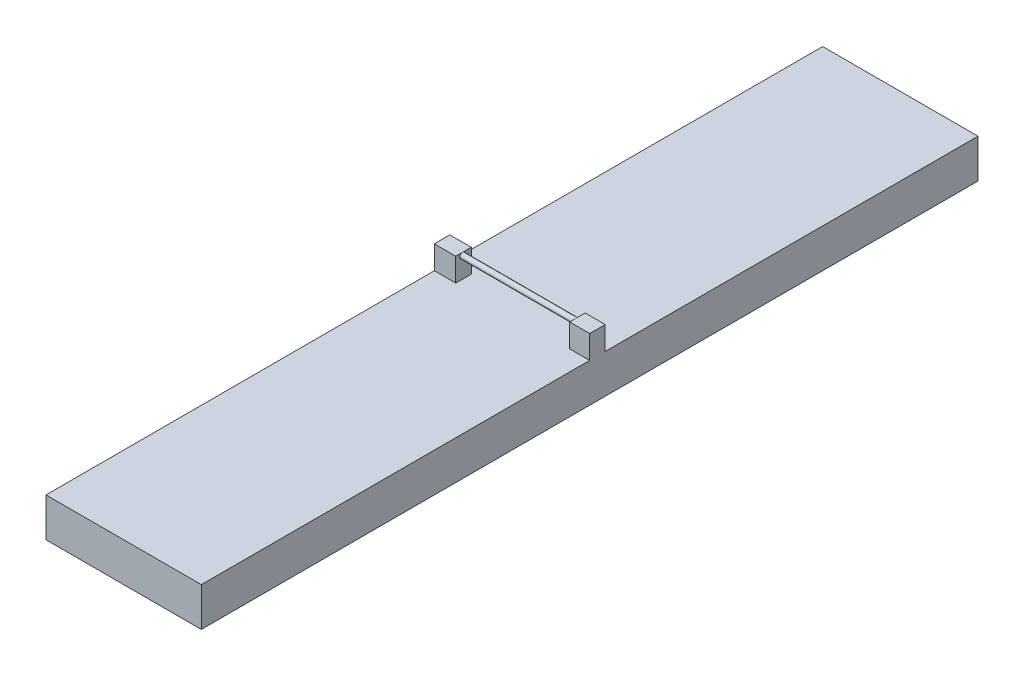
from build123d import *

# Parameters (mm, degrees)
BOSS_EXTRU_2_DEPTH      = 100
BOSS_EXTRU_2_DEPTH_BACK = 100
ESQUISSE3_W             = 1000
ESQUISSE3_H             = 50
ESQUISSE4_W             = 27.549124878
ESQUISSE4_H             = 20
ESQUISSE4_W_2           = 25.7645404
BOSS_EXTRU_4_DEPTH      = 30
BOSS_EXTRU_5_DEPTH      = 157
BOSS_EXTRU_5_DEPTH_BACK = 15
ESQUISSE7_R             = 3.448131388


with BuildPart() as part:
    # Esquisse3 → Boss.-Extru.2 (new, two sides: drawn at the far end of the back side and taken through both)
    with BuildSketch(Plane(origin=(0, 0, 0), x_dir=(0, 0, -1), z_dir=(1, 0, 0)).offset(-BOSS_EXTRU_2_DEPTH_BACK)):
        with Locations((450, 13.600000315)):
            Rectangle(ESQUISSE3_W, ESQUISSE3_H)
    extrude(amount=BOSS_EXTRU_2_DEPTH + BOSS_EXTRU_2_DEPTH_BACK)

    # Esquisse4 → Boss.-Extru.4 (add)
    with BuildSketch(Plane(origin=(0, 38.600000315, 0), x_dir=(1, 0, 0), z_dir=(0, 1, 0))):
        with Locations((-86.225437561, 460)):
            Rectangle(ESQUISSE4_W, ESQUISSE4_H)
        with Locations((87.1177298, 460)):
            Rectangle(ESQUISSE4_W_2, ESQUISSE4_H)
    extrude(amount=BOSS_EXTRU_4_DEPTH)

    # Esquisse7 → Boss.-Extru.5 (add, two sides: drawn at the far end of the back side and taken through both)
    with BuildSketch(Plane(origin=(-72.450875122, 0, 0), x_dir=(0, 0, -1), z_dir=(1, 0, 0)).offset(-BOSS_EXTRU_5_DEPTH_BACK)):
        with Locations((458.615528394, 65.151868928)):
            Circle(ESQUISSE7_R)
    extrude(amount=BOSS_EXTRU_5_DEPTH + BOSS_EXTRU_5_DEPTH_BACK)


solid = part.part
